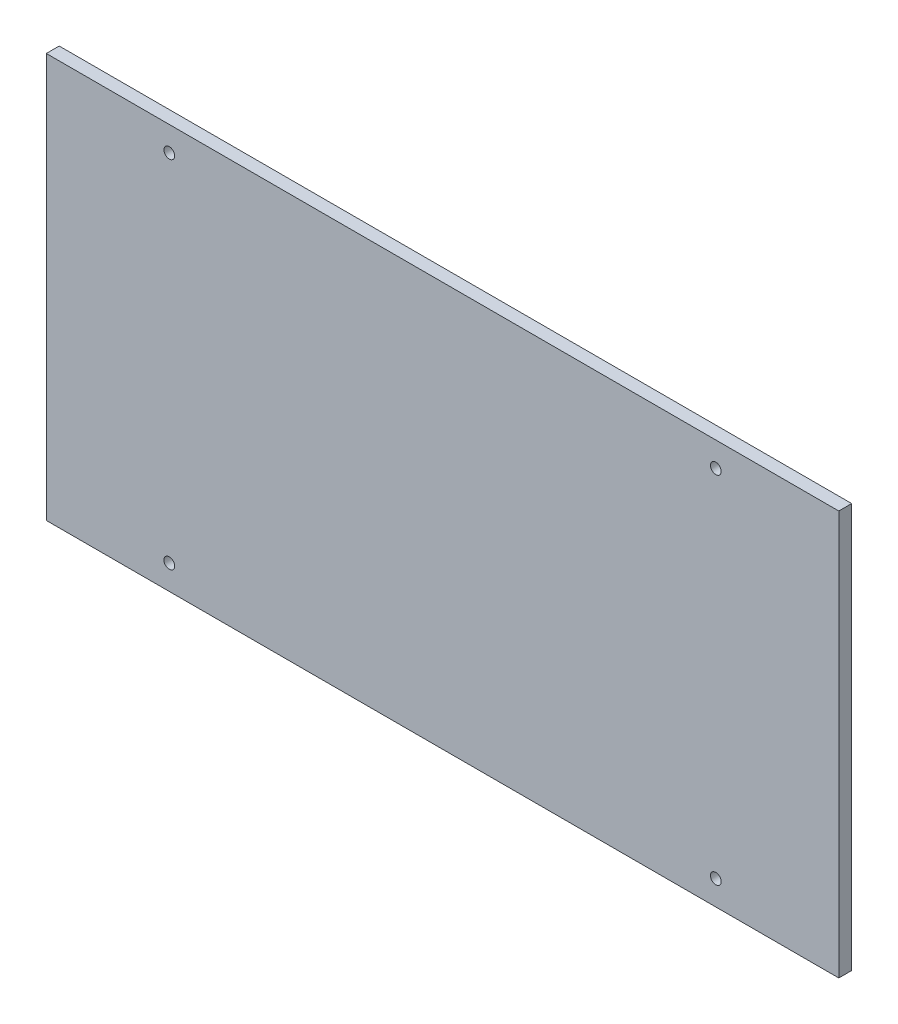
from build123d import *

# Parameters (mm, degrees)
SKETCH2_W           = 184.15
SKETCH2_H           = 93.98
SKETCH2_R           = 1.25
BOSS_EXTRUDE1_DEPTH = 3


with BuildPart() as part:
    # Sketch2 → Boss-Extrude1 (new body)
    with BuildSketch(Plane.XY):
        Rectangle(SKETCH2_W, SKETCH2_H)
        with Locations((-63.5, 41.275)):
            Circle(SKETCH2_R, mode=Mode.SUBTRACT)
        with Locations((63.5, -41.275)):
            Circle(SKETCH2_R, mode=Mode.SUBTRACT)
        with Locations((-63.5, -41.275)):
            Circle(SKETCH2_R, mode=Mode.SUBTRACT)
        with Locations((63.5, 41.275)):
            Circle(SKETCH2_R, mode=Mode.SUBTRACT)
    extrude(amount=BOSS_EXTRUDE1_DEPTH)


solid = part.part
